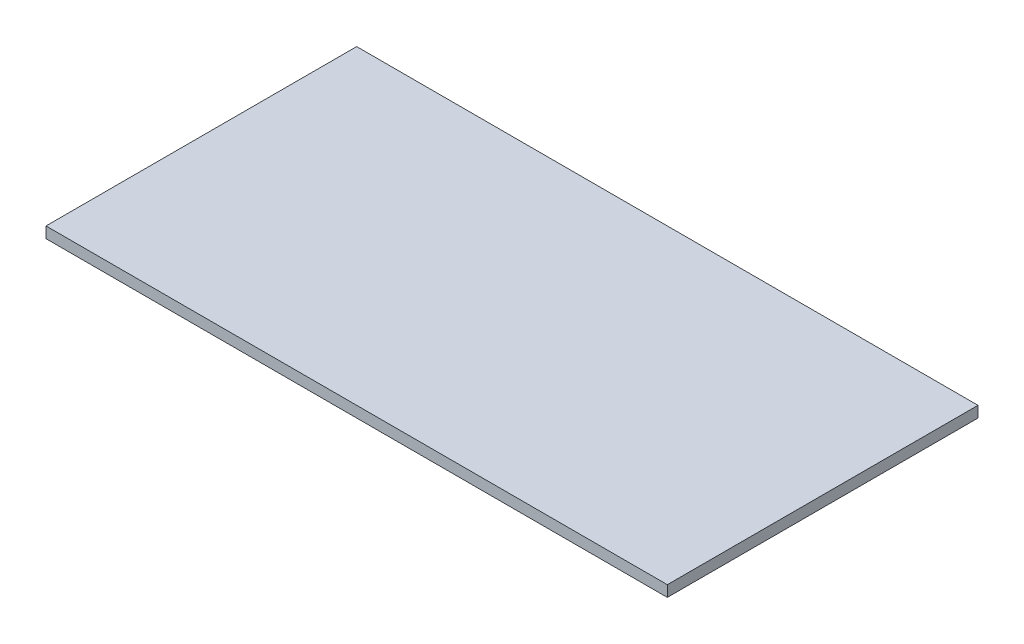
from build123d import *

# Parameters (mm, degrees)
SKETCH1_W           = 90
SKETCH1_H           = 45
BOSS_EXTRUDE1_DEPTH = 1.6


with BuildPart() as part:
    # Sketch1 → Boss-Extrude1 (new body)
    with BuildSketch(Plane(origin=(0, 0, 0), x_dir=(1, 0, 0), z_dir=(0, 1, 0))):
        with Locations((6.493902439, -2.286585366)):
            Rectangle(SKETCH1_W, SKETCH1_H)
    extrude(amount=BOSS_EXTRUDE1_DEPTH)


solid = part.part
